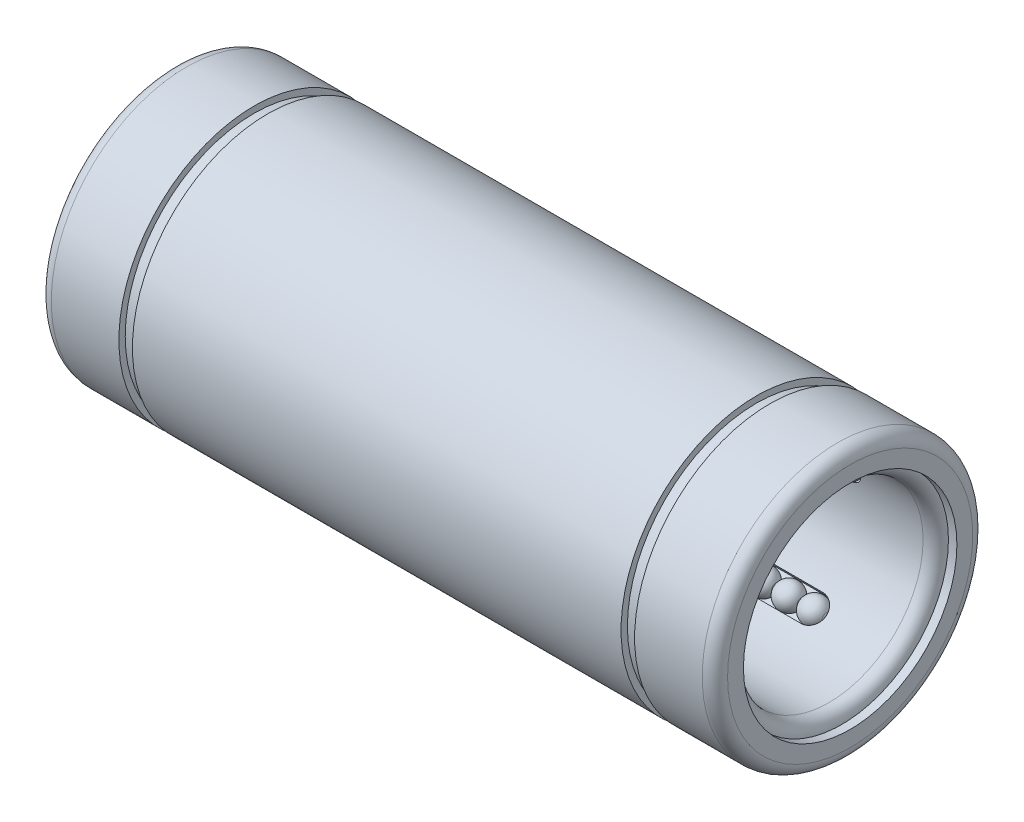
from build123d import *

# Parameters (mm, degrees)
PATTERN_LINEAR_1_COUNT   = 7
PATTERN_LINEAR_1_PITCH   = 3
PATTERN_CIRCULAR_1_COUNT = 5
CUT_EXTRUDE_1_DEPTH      = 16.25
PATTERN_CIRCULAR_2_COUNT = 5


with BuildPart() as part:
    # Sketch 2 → Revolve 1 (revolve)
    with BuildSketch(Plane.XY):
        with BuildLine():
            Line((-30.5, 11.5), (-27.5, 11.5))
            Line((-27.5, 11.5), (-27.5, 11.25))
            Line((-27.5, 11.25), (-27.581081081, 11.013513514))
            ThreePointArc((-27.581081081, 11.013513514), (-29, 10), (-30.418918919, 11.013513514))
            Line((-30.418918919, 11.013513514), (-30.5, 11.25))
            Line((-30.5, 11.25), (-30.5, 11.5))
        make_face()
    revolve(axis=Axis((-27.5, 11.5, 0), (1, 0, 0)))


with BuildPart() as pattern_linear_1_1:
    # Pattern Linear 1: pattern copy
    add(part.part.moved(Location(Vector(1, 0, 0) * (1 * PATTERN_LINEAR_1_PITCH))))


with BuildPart() as pattern_linear_1_2:
    # Pattern Linear 1: pattern copy
    add(part.part.moved(Location(Vector(1, 0, 0) * (2 * PATTERN_LINEAR_1_PITCH))))


with BuildPart() as pattern_linear_1_3:
    # Pattern Linear 1: pattern copy
    add(part.part.moved(Location(Vector(1, 0, 0) * (3 * PATTERN_LINEAR_1_PITCH))))


with BuildPart() as pattern_linear_1_4:
    # Pattern Linear 1: pattern copy
    add(part.part.moved(Location(Vector(1, 0, 0) * (4 * PATTERN_LINEAR_1_PITCH))))


with BuildPart() as pattern_linear_1_5:
    # Pattern Linear 1: pattern copy
    add(part.part.moved(Location(Vector(1, 0, 0) * (5 * PATTERN_LINEAR_1_PITCH))))


with BuildPart() as pattern_linear_1_6:
    # Pattern Linear 1: pattern copy
    add(part.part.moved(Location(Vector(1, 0, 0) * (6 * PATTERN_LINEAR_1_PITCH))))


with BuildPart() as part_1:
    add(part.part)

    # Combine 2: union Pattern Linear 1_1, Pattern Linear 1_2, Pattern Linear 1_3, Pattern Linear 1_4, Pattern Linear 1_5, Pattern Linear 1_6
    add(pattern_linear_1_1.part)
    add(pattern_linear_1_2.part)
    add(pattern_linear_1_3.part)
    add(pattern_linear_1_4.part)
    add(pattern_linear_1_5.part)
    add(pattern_linear_1_6.part)


with BuildPart() as pattern_circular_1_1:
    # Pattern Circular 1: pattern copy
    add(part_1.part.rotate(Axis((0, 0, 0), (1, 0, 0)), 1 * 360 / PATTERN_CIRCULAR_1_COUNT))


with BuildPart() as pattern_circular_1_2:
    # Pattern Circular 1: pattern copy
    add(part_1.part.rotate(Axis((0, 0, 0), (1, 0, 0)), 2 * 360 / PATTERN_CIRCULAR_1_COUNT))


with BuildPart() as pattern_circular_1_3:
    # Pattern Circular 1: pattern copy
    add(part_1.part.rotate(Axis((0, 0, 0), (1, 0, 0)), 3 * 360 / PATTERN_CIRCULAR_1_COUNT))


with BuildPart() as pattern_circular_1_4:
    # Pattern Circular 1: pattern copy
    add(part_1.part.rotate(Axis((0, 0, 0), (1, 0, 0)), 4 * 360 / PATTERN_CIRCULAR_1_COUNT))


with BuildPart() as body_6:
    # Sketch 3 → Revolve 2 (revolve)
    with BuildSketch(Plane.XY):
        with BuildLine():
            Line((-39, 15.25), (-38.25, 15.25))
            Line((-38.25, 15.25), (-38.25, 12.625))
            ThreePointArc((-38.25, 12.625), (-38.030330086, 12.094669914), (-37.5, 11.875))
            Line((-37.5, 11.875), (0, 11.875))
            Line((0, 11.875), (0, 11.125))
            Line((0, 11.125), (-37.5, 11.125))
            ThreePointArc((-37.5, 11.125), (-38.560660172, 11.564339828), (-39, 12.625))
            Line((-39, 12.625), (-39, 15.25))
        make_face()
    revolve(axis=Axis((0, 0, 0), (-1, 0, 0)))

    # Sketch 4 → Cut-Extrude 1 (cut, through all)
    with BuildSketch(Plane(origin=(0, 0, 0), x_dir=(1, 0, 0), z_dir=(0, 1, 0))):
        with BuildLine():
            Line((-29, 1.6), (-11, 1.6))
            ThreePointArc((-11, 1.6), (-9.4, 0), (-11, -1.6))
            Line((-11, -1.6), (-29, -1.6))
            ThreePointArc((-29, -1.6), (-30.6, 0), (-29, 1.6))
        make_face()
    cut_extrude_1 = extrude(amount=CUT_EXTRUDE_1_DEPTH, mode=Mode.SUBTRACT)

    # Pattern Circular 2: Cut-Extrude 1 ×5 about axis
    pattern_circular_2_axis = Axis((0, 0, 0), (1, 0, 0))
    for i in range(1, PATTERN_CIRCULAR_2_COUNT):
        add(cut_extrude_1.rotate(pattern_circular_2_axis, i * 360 / PATTERN_CIRCULAR_2_COUNT), mode=Mode.SUBTRACT)

    # Mirror 5: body 6 across plane


with BuildPart() as body_7:
    # Sketch 5 → Revolve 3 (revolve)
    with BuildSketch(Plane.XY):
        with BuildLine():
            Line((-38.5, 16), (-30.5, 16))
            Line((-30.5, 16), (-30.5, 15.25))
            Line((-30.5, 15.25), (-28.9, 15.25))
            Line((-28.9, 15.25), (-28.9, 16))
            Line((-28.9, 16), (0, 16))
            Line((0, 16), (0, 11.875))
            Line((0, 11.875), (-9.035470794, 11.875))
            ThreePointArc((-9.035470794, 11.875), (-9.725245122, 13.041103501), (-11, 13.5))
            Line((-11, 13.5), (-29, 13.5))
            ThreePointArc((-29, 13.5), (-30.274754878, 13.041103501), (-30.964529206, 11.875))
            Line((-30.964529206, 11.875), (-37.5, 11.875))
            ThreePointArc((-37.5, 11.875), (-38.030330086, 12.094669914), (-38.25, 12.625))
            Line((-38.25, 12.625), (-38.25, 15.25))
            Line((-38.25, 15.25), (-39, 15.25))
            Line((-39, 15.25), (-39, 12.625))
            Line((-39, 12.625), (-40, 12.625))
            Line((-40, 12.625), (-40, 14.5))
            ThreePointArc((-40, 14.5), (-39.560660172, 15.560660172), (-38.5, 16))
        make_face()
    revolve(axis=Axis((0, 0, 0), (-1, 0, 0)))

    # Mirror 5 2: body 7 across plane


with BuildPart() as body_8:
    # Mirror 4: mirrored copy
    add(part_1.part.mirror(Plane(origin=(0, -17.481620331, 0), x_dir=(0, 0, 1), z_dir=(-1, 0, 0))))


with BuildPart() as body_9:
    # Mirror 4 2: mirrored copy
    add(pattern_circular_1_1.part.mirror(Plane(origin=(0, -17.481620331, 0), x_dir=(0, 0, 1), z_dir=(-1, 0, 0))))


with BuildPart() as body_10:
    # Mirror 4 3: mirrored copy
    add(pattern_circular_1_2.part.mirror(Plane(origin=(0, -17.481620331, 0), x_dir=(0, 0, 1), z_dir=(-1, 0, 0))))


with BuildPart() as body_11:
    # Mirror 4 4: mirrored copy
    add(pattern_circular_1_3.part.mirror(Plane(origin=(0, -17.481620331, 0), x_dir=(0, 0, 1), z_dir=(-1, 0, 0))))


with BuildPart() as body_12:
    # Mirror 4 5: mirrored copy
    add(pattern_circular_1_4.part.mirror(Plane(origin=(0, -17.481620331, 0), x_dir=(0, 0, 1), z_dir=(-1, 0, 0))))


with BuildPart() as body_6_1:
    add(body_6.part)
    add(body_6.part.mirror(Plane(origin=(0, -17.481620331, 0), x_dir=(0, 0, 1), z_dir=(-1, 0, 0))))


with BuildPart() as body_7_1:
    add(body_7.part)
    add(body_7.part.mirror(Plane(origin=(0, -17.481620331, 0), x_dir=(0, 0, 1), z_dir=(-1, 0, 0))))


solid = Compound([part_1.part, pattern_circular_1_1.part, pattern_circular_1_2.part, pattern_circular_1_3.part, pattern_circular_1_4.part, body_8.part, body_9.part, body_10.part, body_11.part, body_12.part, body_6_1.part, body_7_1.part])
